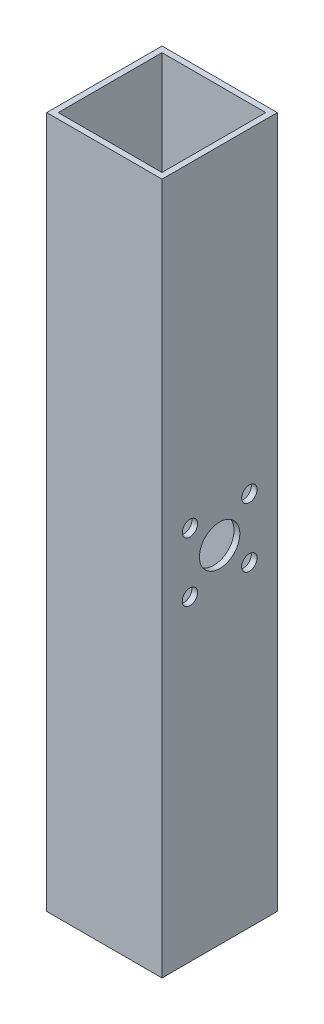
from build123d import *

# Parameters (mm, degrees)
SKETCH1_W           = 76.2
SKETCH1_H           = 76.2
SKETCH1_W_2         = 68.58
SKETCH1_H_2         = 68.58
BOSS_EXTRUDE1_DEPTH = 457.2
SKETCH2_R           = 13.335
CUT_EXTRUDE1_DEPTH  = 914.4
SKETCH3_R           = 5.08
CUT_EXTRUDE2_DEPTH  = 914.4


with BuildPart() as part:
    # Sketch1 → Boss-Extrude1 (new body)
    with BuildSketch(Plane(origin=(0, 0, 0), x_dir=(1, 0, 0), z_dir=(0, 1, 0))):
        with Locations((38.1, 38.1)):
            Rectangle(SKETCH1_W, SKETCH1_H)
        with Locations((38.1, 38.1)):
            Rectangle(SKETCH1_W_2, SKETCH1_H_2, mode=Mode.SUBTRACT)
    extrude(amount=BOSS_EXTRUDE1_DEPTH)

    # Sketch2 → Cut-Extrude1 (cut)
    with BuildSketch(Plane.ZY):
        with Locations((-38.1, 228.6)):
            Circle(SKETCH2_R)
    extrude(amount=-CUT_EXTRUDE1_DEPTH, mode=Mode.SUBTRACT)

    # Sketch3 → Cut-Extrude2 (cut)
    with BuildSketch(Plane.ZY):
        with Locations((-57.742411839, 248.242411839)):
            Circle(SKETCH3_R)
        with Locations((-18.457588161, 248.242411839)):
            Circle(SKETCH3_R)
        with Locations((-57.742411839, 208.957588161)):
            Circle(SKETCH3_R)
        with Locations((-18.457588161, 208.957588161)):
            Circle(SKETCH3_R)
    extrude(amount=-CUT_EXTRUDE2_DEPTH, mode=Mode.SUBTRACT)


solid = part.part
